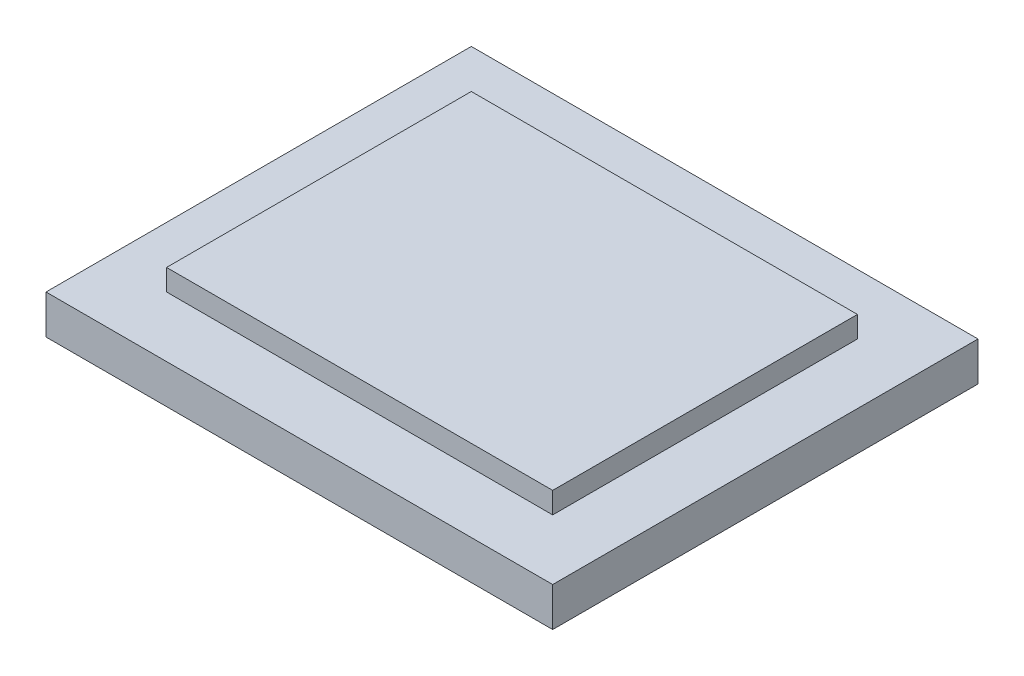
from build123d import *

# Parameters (mm, degrees)
SKETCH1_W           = 151.3
SKETCH1_H           = 127
BOSS_EXTRUDE1_DEPTH = 18
SKETCH3_W           = 18
SKETCH3_H           = 127
CUT_EXTRUDE2_DEPTH  = 6.35
SKETCH2_W           = 151.3
SKETCH2_H           = 18
CUT_EXTRUDE3_DEPTH  = 6.35


with BuildPart() as part:
    # Sketch1 → Boss-Extrude1 (new body)
    with BuildSketch(Plane(origin=(0, 0, 0), x_dir=(1, 0, 0), z_dir=(0, 1, 0))):
        Rectangle(SKETCH1_W, SKETCH1_H)
    extrude(amount=BOSS_EXTRUDE1_DEPTH)

    # Sketch3 → Cut-Extrude2 (cut)
    with BuildSketch(Plane(origin=(0, 18, 0), x_dir=(1, 0, 0), z_dir=(0, 1, 0))):
        with Locations((66.65, 0)):
            Rectangle(SKETCH3_W, SKETCH3_H)
        with Locations((-66.65, 0)):
            Rectangle(SKETCH3_W, SKETCH3_H)
    extrude(amount=-CUT_EXTRUDE2_DEPTH, mode=Mode.SUBTRACT)

    # Sketch2 → Cut-Extrude3 (cut)
    with BuildSketch(Plane(origin=(0, 18, 0), x_dir=(1, 0, 0), z_dir=(0, 1, 0))):
        with Locations((0, -54.5)):
            Rectangle(SKETCH2_W, SKETCH2_H)
        with Locations((0, 54.5)):
            Rectangle(SKETCH2_W, SKETCH2_H)
    extrude(amount=-CUT_EXTRUDE3_DEPTH, mode=Mode.SUBTRACT)


solid = part.part
